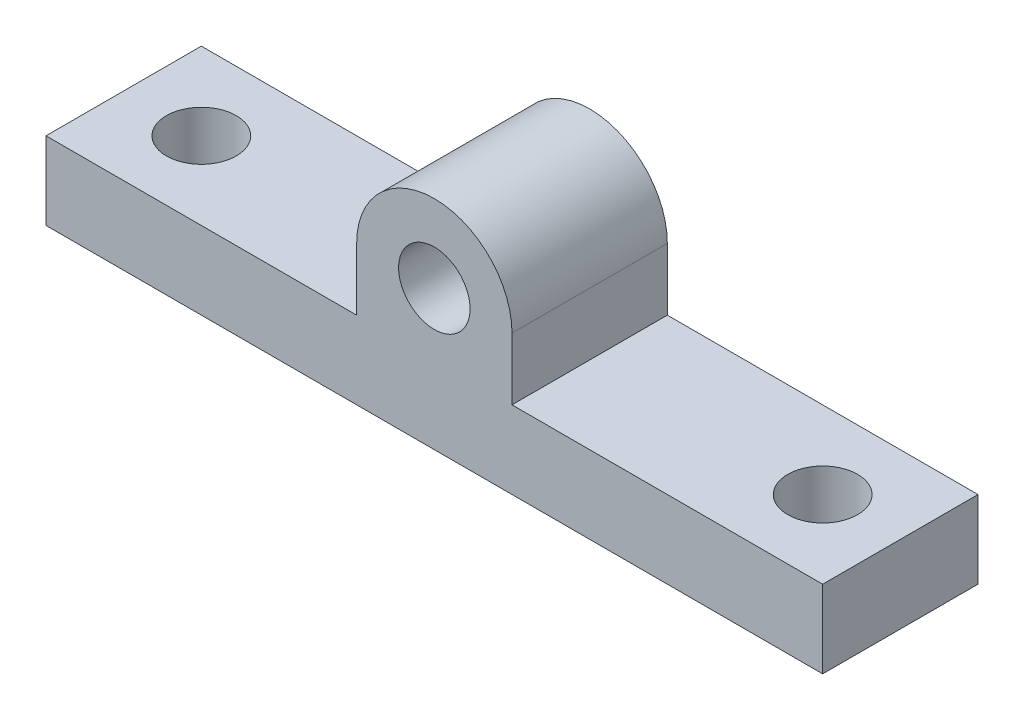
from build123d import *

# Parameters (mm, degrees)
SKETCH1_W           = 50
SKETCH1_H           = 10
SKETCH1_R           = 2.25
BOSS_EXTRUDE1_DEPTH = 5
SKETCH3_R           = 2.3
BOSS_EXTRUDE2_DEPTH = 10


with BuildPart() as part:
    # Sketch1 → Boss-Extrude1 (new body)
    with BuildSketch(Plane(origin=(0, 0, 0), x_dir=(1, 0, 0), z_dir=(0, 1, 0))):
        Rectangle(SKETCH1_W, SKETCH1_H)
        with Locations((-20, 0)):
            Circle(SKETCH1_R, mode=Mode.SUBTRACT)
        with Locations((20, 0)):
            Circle(SKETCH1_R, mode=Mode.SUBTRACT)
    extrude(amount=BOSS_EXTRUDE1_DEPTH)

    # Sketch3 → Boss-Extrude2 (add)
    with BuildSketch(Plane.XY.offset(5)):
        with BuildLine():
            Line((-5, 5), (-5, 9))
            ThreePointArc((-5, 9), (0, 14), (5, 9))
            Line((5, 9), (5, 5))
            Line((5, 5), (-5, 5))
        make_face()
        with Locations((0, 9)):
            Circle(SKETCH3_R, mode=Mode.SUBTRACT)
    extrude(amount=-BOSS_EXTRUDE2_DEPTH)


solid = part.part
